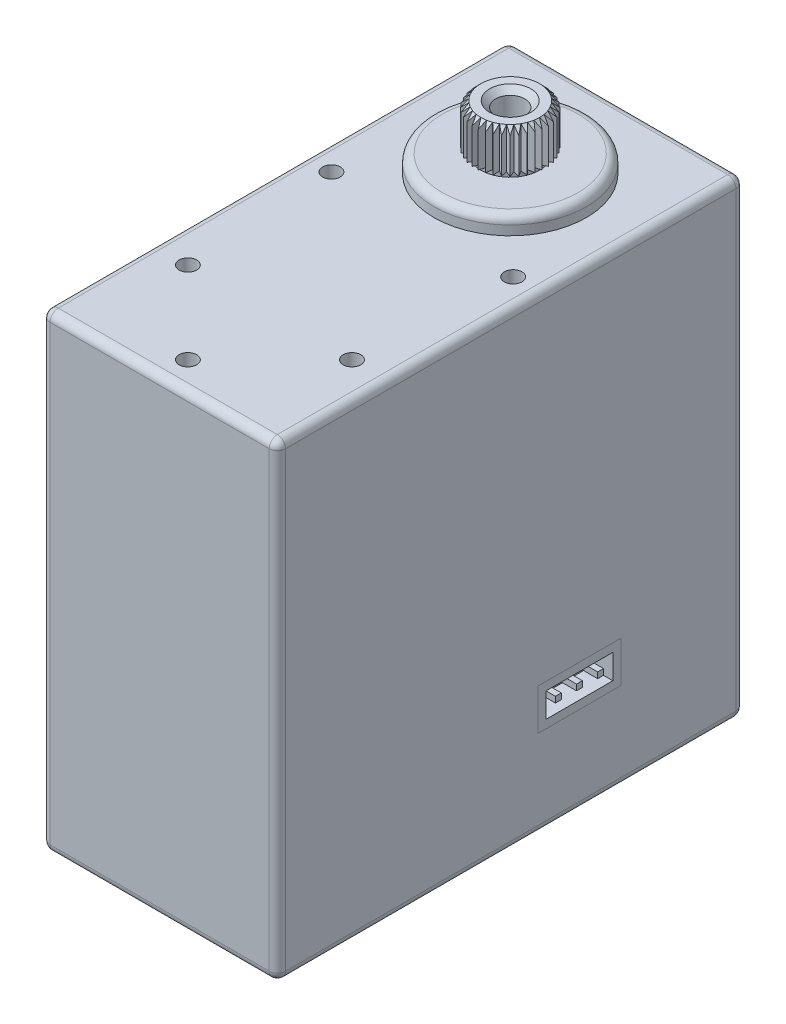
from build123d import *

# Parameters (mm, degrees)
CROQUIS2_R                 = 3
SALIENTE_EXTRUIR1_DEPTH    = 5.4
CROQUIS2_4_R               = 6.5
SALIENTE_EXTRUIR2_DEPTH    = 1.5
CROQUIS2_6_W               = 20.09
CROQUIS2_6_H               = 39.82
SALIENTE_EXTRUIR3_DEPTH    = 40
CROQUIS2_7_R               = 0.75
CORTAR_EXTRUIR1_DEPTH      = 2
CROQUIS2_8_R               = 6.5
SALIENTE_EXTRUIR4_DEPTH    = 41.5
CROQUIS2_10_R              = 3
SALIENTE_EXTRUIR5_DEPTH    = 45.7
CROQUIS3_R                 = 0.75
CORTAR_EXTRUIR2_DEPTH      = 2
CROQUIS5_W                 = 7.09
CROQUIS5_H                 = 3.5
CROQUIS5_W_2               = 5.69
CROQUIS5_H_2               = 2.1
CORTAR_EXTRUIR5_DEPTH      = 2
CROQUIS5_4_W               = 7.09
CROQUIS5_4_H               = 3.5
CROQUIS5_4_W_2             = 5.69
CROQUIS5_4_H_2             = 2.1
SALIENTE_EXTRUIR6_DEPTH    = 2
CROQUIS8_W                 = 7.09
CROQUIS8_H                 = 3.5
CROQUIS8_W_2               = 5.69
CROQUIS8_H_2               = 2.1
CORTAR_EXTRUIR6_DEPTH      = 2
CROQUIS8_6_W               = 7.09
CROQUIS8_6_H               = 3.5
CROQUIS8_6_W_2             = 5.69
CROQUIS8_6_H_2             = 2.1
SALIENTE_EXTRUIR9_DEPTH    = 2
REDONDEO1_R                = 0.7
REDONDEO2_R                = 0.7
CHAFL_N1_SIZE              = 0.5
CROQUIS9_R                 = 5.8
CORTAR_EXTRUIR13_DEPTH     = 3.5
CROQUIS10_R                = 3
CROQUIS10_R_2              = 2.5
CORTAR_EXTRUIR15_DEPTH     = 0.4
CROQUIS11_R                = 1.25
CORTAR_EXTRUIR16_DEPTH     = 4
CHAFL_N2_SIZE              = 0.5
CROQUIS12_W                = 0.5
CROQUIS12_H                = 0.5
SALIENTE_EXTRUIR13_DEPTH   = 2
SALIENTE_EXTRUIR13_2_DEPTH = 2
SALIENTE_EXTRUIR13_3_DEPTH = 2
CROQUIS13_W                = 0.5
CROQUIS13_H                = 0.5
SALIENTE_EXTRUIR14_DEPTH   = 2
SALIENTE_EXTRUIR14_2_DEPTH = 2
SALIENTE_EXTRUIR14_3_DEPTH = 2


with BuildPart() as part:
    # Croquis2 → Saliente-Extruir1 (new body)
    with BuildSketch(Plane(origin=(0, 0, 0), x_dir=(1, 0, 0), z_dir=(0, 1, 0))):
        with Locations(Location((0, 0, 0), (0, 0, 90))):
            Circle(CROQUIS2_R)
    extrude(amount=SALIENTE_EXTRUIR1_DEPTH)

    # Croquis2_4 → Saliente-Extruir2 (add)
    with BuildSketch(Plane(origin=(0, 0, 0), x_dir=(1, 0, 0), z_dir=(0, 1, 0))):
        with Locations(Location((0, 0, 0), (0, 0, 270))):
            Circle(CROQUIS2_4_R)
    extrude(amount=SALIENTE_EXTRUIR2_DEPTH)



with BuildPart() as body_2:
    # Croquis2_6 → Saliente-Extruir3 (new body)
    with BuildSketch(Plane(origin=(0, 0, 0), x_dir=(1, 0, 0), z_dir=(0, 1, 0))):
        with Locations((0, -10)):
            Rectangle(CROQUIS2_6_W, CROQUIS2_6_H)
    extrude(amount=-SALIENTE_EXTRUIR3_DEPTH)

    # Croquis2_7 → Cortar-Extruir1 (cut)
    with BuildSketch(Plane(origin=(0, 0, 0), x_dir=(1, 0, 0), z_dir=(0, 1, 0))):
        with Locations(Location((0, -27.5, 0), (0, 0, 270))):
            Circle(CROQUIS2_7_R)
        with Locations(Location((7, -20.5, 0), (0, 0, 270))):
            Circle(CROQUIS2_7_R)
        with Locations(Location((-7, -20.5, 0), (0, 0, 270))):
            Circle(CROQUIS2_7_R)
        with Locations(Location((-7.75, -7.5, 0), (0, 0, 270))):
            Circle(CROQUIS2_7_R)
        with Locations(Location((7.75, -7.5, 0), (0, 0, 270))):
            Circle(CROQUIS2_7_R)
    extrude(amount=-CORTAR_EXTRUIR1_DEPTH, mode=Mode.SUBTRACT)


with BuildPart() as part_1:
    add(part.part)

    add(body_2.part)  # Saliente-Extruir4 merges body 2
    # Croquis2_8 → Saliente-Extruir4 (add)
    with BuildSketch(Plane(origin=(0, 0, 0), x_dir=(1, 0, 0), z_dir=(0, 1, 0))):
        with Locations(Location((0, 0, 0), (0, 0, 270))):
            Circle(CROQUIS2_8_R)
    extrude(amount=-SALIENTE_EXTRUIR4_DEPTH)

    # Croquis2_10 → Saliente-Extruir5 (add)
    with BuildSketch(Plane(origin=(0, 0, 0), x_dir=(1, 0, 0), z_dir=(0, 1, 0))):
        with Locations(Location((0, 0, 0), (0, 0, 90))):
            Circle(CROQUIS2_10_R)
    extrude(amount=-SALIENTE_EXTRUIR5_DEPTH)

    # Croquis3 → Cortar-Extruir2 (cut)
    with BuildSketch(Plane.XZ.offset(40)):
        with Locations(Location((-7.5, 12.5, 0), (0, 0, 270))):
            Circle(CROQUIS3_R)
        with Locations(Location((-7.5, -7.5, 0), (0, 0, 270))):
            Circle(CROQUIS3_R)
        with Locations(Location((-7.5, 27.5, 0), (0, 0, 270))):
            Circle(CROQUIS3_R)
        with Locations(Location((7.5, -7.5, 0), (0, 0, 90))):
            Circle(CROQUIS3_R)
        with Locations(Location((7.5, 12.5, 0), (0, 0, 90))):
            Circle(CROQUIS3_R)
        with Locations(Location((7.5, 27.5, 0), (0, 0, 90))):
            Circle(CROQUIS3_R)
    extrude(amount=-CORTAR_EXTRUIR2_DEPTH, mode=Mode.SUBTRACT)

    # Croquis5 → Cortar-Extruir5 (cut)
    with BuildSketch(Plane(origin=(0, 0, -9.91), x_dir=(-1, 0, 0), z_dir=(0, 0, -1))):
        with Locations((0, -30.75)):
            Rectangle(CROQUIS5_W, CROQUIS5_H)
        with Locations((0, -30.75)):
            Rectangle(CROQUIS5_W_2, CROQUIS5_H_2, mode=Mode.SUBTRACT)
        with Locations((0, -30.75)):
            Rectangle(CROQUIS5_W_2, CROQUIS5_H_2)
    extrude(amount=-CORTAR_EXTRUIR5_DEPTH, mode=Mode.SUBTRACT)

    # Croquis8 → Cortar-Extruir6 (cut)
    with BuildSketch(Plane.ZY.offset(10.045)):
        with Locations((4.135, -30.75)):
            Rectangle(CROQUIS8_W, CROQUIS8_H)
        with Locations((4.135, -30.75)):
            Rectangle(CROQUIS8_W_2, CROQUIS8_H_2, mode=Mode.SUBTRACT)
        with Locations((4.135, -30.75)):
            Rectangle(CROQUIS8_W_2, CROQUIS8_H_2)
    cortar_extruir6 = extrude(amount=-CORTAR_EXTRUIR6_DEPTH, mode=Mode.SUBTRACT)

    # Simetría1: Cortar-Extruir6 across plane
    add(cortar_extruir6.mirror(Plane(origin=(0, 0, 0), x_dir=(0, 0, 1), z_dir=(1, 0, 0))), mode=Mode.SUBTRACT)

    # Redondeo1
    redondeo1_edges = [part_1.edges().sort_by_distance(p)[0] for p in [
        (0, 0, 29.91),
        (10.045, 0, 10),
        (-10.045, 0, 10),
        (-10.045, -20, 29.91),
        (0, 0, -9.91),
        (-10.045, -20, -9.91),
        (10.045, -40, 10),
        (10.045, -20, -9.91),
        (0, -40, 29.91),
        (10.045, -20, 29.91),
        (-10.045, -40, 10),
        (0, -40, -9.91),
    ]]
    fillet(redondeo1_edges, radius=REDONDEO1_R)

    # Redondeo2
    redondeo2_edges = [part_1.edges().sort_by_distance(p)[0] for p in [
        (0, -41.5, -6.5),
        (0, -41.5, 3),
        (0, 1.5, -6.5),
    ]]
    fillet(redondeo2_edges, radius=REDONDEO2_R)

    # Chaflán1
    chafl_n1_edges = [part_1.edges().sort_by_distance(p)[0] for p in [
        (0, 5.4, 3),
    ]]
    chamfer(chafl_n1_edges, length=CHAFL_N1_SIZE)

    # Croquis9 → Cortar-Extruir13 (cut)
    with BuildSketch(Plane(origin=(0, 5.4, 0), x_dir=(1, 0, 0), z_dir=(0, 1, 0))):
        Circle(CROQUIS9_R)
        Polygon((0, 2.5), (0.261467228, 2.988584094), (0.434120444, 2.462019383), (0.776457135, 2.897777479), (0.855050358, 2.349231552), (1.267854785, 2.718923361), (1.25, 2.165063509), (1.720729309, 2.457456133), (1.606969024, 1.915111108), (2.121320344, 2.121320344), (1.915111108, 1.606969024), (2.457456133, 1.720729309), (2.165063509, 1.25), (2.718923361, 1.267854785), (2.349231552, 0.855050358), (2.897777479, 0.776457135), (2.462019383, 0.434120444), (2.988584094, 0.261467228), (2.5, 0), (2.988584094, -0.261467228), (2.462019383, -0.434120444), (2.897777479, -0.776457135), (2.349231552, -0.855050358), (2.718923361, -1.267854785), (2.165063509, -1.25), (2.457456133, -1.720729309), (1.915111108, -1.606969024), (2.121320344, -2.121320344), (1.606969024, -1.915111108), (1.720729309, -2.457456133), (1.25, -2.165063509), (1.267854785, -2.718923361), (0.855050358, -2.349231552), (0.776457135, -2.897777479), (0.434120444, -2.462019383), (0.261467228, -2.988584094), (0, -2.5), (-0.261467228, -2.988584094), (-0.434120444, -2.462019383), (-0.776457135, -2.897777479), (-0.855050358, -2.349231552), (-1.267854785, -2.718923361), (-1.25, -2.165063509), (-1.720729309, -2.457456133), (-1.606969024, -1.915111108), (-2.121320344, -2.121320344), (-1.915111108, -1.606969024), (-2.457456133, -1.720729309), (-2.165063509, -1.25), (-2.718923361, -1.267854785), (-2.349231552, -0.855050358), (-2.897777479, -0.776457135), (-2.462019383, -0.434120444), (-2.988584094, -0.261467228), (-2.5, 0), (-2.988584094, 0.261467228), (-2.462019383, 0.434120444), (-2.897777479, 0.776457135), (-2.349231552, 0.855050358), (-2.718923361, 1.267854785), (-2.165063509, 1.25), (-2.457456133, 1.720729309), (-1.915111108, 1.606969024), (-2.121320344, 2.121320344), (-1.606969024, 1.915111108), (-1.720729309, 2.457456133), (-1.25, 2.165063509), (-1.267854785, 2.718923361), (-0.855050358, 2.349231552), (-0.776457135, 2.897777479), (-0.434120444, 2.462019383), (-0.261467228, 2.988584094), align=None, mode=Mode.SUBTRACT)
    extrude(amount=-CORTAR_EXTRUIR13_DEPTH, mode=Mode.SUBTRACT)

    # Croquis10 → Cortar-Extruir15 (cut)
    with BuildSketch(Plane(origin=(0, 1.9, 0), x_dir=(1, 0, 0), z_dir=(0, 1, 0))):
        with Locations(Location((0, 0, 0), (0, 0, 270))):
            Circle(CROQUIS10_R)
        with Locations(Location((0, 0, 0), (0, 0, 270))):
            Circle(CROQUIS10_R_2, mode=Mode.SUBTRACT)
    extrude(amount=-CORTAR_EXTRUIR15_DEPTH, mode=Mode.SUBTRACT)

    # Croquis11 → Cortar-Extruir16 (cut)
    with BuildSketch(Plane(origin=(0, 5.4, 0), x_dir=(1, 0, 0), z_dir=(0, 1, 0))):
        with Locations(Location((0, 0, 0), (0, 0, 270))):
            Circle(CROQUIS11_R)
    extrude(amount=-CORTAR_EXTRUIR16_DEPTH, mode=Mode.SUBTRACT)

    # Chaflán2
    chafl_n2_edges = [part_1.edges().sort_by_distance(p)[0] for p in [
        (0, 5.4, -1.25),
    ]]
    chamfer(chafl_n2_edges, length=CHAFL_N2_SIZE)


with BuildPart() as body_2_2:
    # Croquis5_4 → Saliente-Extruir6 (new body)
    with BuildSketch(Plane(origin=(0, 0, -9.91), x_dir=(-1, 0, 0), z_dir=(0, 0, -1))):
        with Locations((0, -30.75)):
            Rectangle(CROQUIS5_4_W, CROQUIS5_4_H)
        with Locations((0, -30.75)):
            Rectangle(CROQUIS5_4_W_2, CROQUIS5_4_H_2, mode=Mode.SUBTRACT)
    extrude(amount=-SALIENTE_EXTRUIR6_DEPTH)


with BuildPart() as body_3:
    # Croquis8_6 → Saliente-Extruir9 (new body)
    with BuildSketch(Plane.ZY.offset(10.045)):
        with Locations((4.135, -30.75)):
            Rectangle(CROQUIS8_6_W, CROQUIS8_6_H)
        with Locations((4.135, -30.75)):
            Rectangle(CROQUIS8_6_W_2, CROQUIS8_6_H_2, mode=Mode.SUBTRACT)
    extrude(amount=-SALIENTE_EXTRUIR9_DEPTH)


with BuildPart() as body_4:
    # Simetría4: mirrored copy
    add(body_3.part.mirror(Plane(origin=(0, 0, 0), x_dir=(0, 0, 1), z_dir=(1, 0, 0))))


with BuildPart() as body_5:
    # Croquis12 → Saliente-Extruir13 (new body)
    with BuildSketch(Plane(origin=(8.045, 0, 0), x_dir=(0, 0, -1), z_dir=(1, 0, 0))):
        with Locations((-2.335, -30.75)):
            Rectangle(CROQUIS12_W, CROQUIS12_H)
    saliente_extruir13 = extrude(amount=SALIENTE_EXTRUIR13_DEPTH)


with BuildPart() as body_6:
    # Croquis12 → Saliente-Extruir13 2 (new body)
    with BuildSketch(Plane(origin=(8.045, 0, 0), x_dir=(0, 0, -1), z_dir=(1, 0, 0))):
        with Locations((-4.135, -30.75)):
            Rectangle(CROQUIS12_W, CROQUIS12_H)
    saliente_extruir13_2 = extrude(amount=SALIENTE_EXTRUIR13_2_DEPTH)


with BuildPart() as body_7:
    # Croquis12 → Saliente-Extruir13 3 (new body)
    with BuildSketch(Plane(origin=(8.045, 0, 0), x_dir=(0, 0, -1), z_dir=(1, 0, 0))):
        with Locations((-5.935, -30.75)):
            Rectangle(CROQUIS12_W, CROQUIS12_H)
    saliente_extruir13_3 = extrude(amount=SALIENTE_EXTRUIR13_3_DEPTH)


with BuildPart() as part_2:
    add(part_1.part)

    # Simetría5: Saliente-Extruir13, Saliente-Extruir13 2, Saliente-Extruir13 3 across plane
    add(saliente_extruir13.mirror(Plane(origin=(0, 0, 0), x_dir=(0, 0, 1), z_dir=(1, 0, 0))))
    add(saliente_extruir13_2.mirror(Plane(origin=(0, 0, 0), x_dir=(0, 0, 1), z_dir=(1, 0, 0))))
    add(saliente_extruir13_3.mirror(Plane(origin=(0, 0, 0), x_dir=(0, 0, 1), z_dir=(1, 0, 0))))


with BuildPart() as body_8:
    # Croquis13 → Saliente-Extruir14 (new body)
    with BuildSketch(Plane(origin=(0, 0, -7.91), x_dir=(-1, 0, 0), z_dir=(0, 0, -1))):
        with Locations((-1.8, -30.75)):
            Rectangle(CROQUIS13_W, CROQUIS13_H)
    extrude(amount=SALIENTE_EXTRUIR14_DEPTH)


with BuildPart() as body_9:
    # Croquis13 → Saliente-Extruir14 2 (new body)
    with BuildSketch(Plane(origin=(0, 0, -7.91), x_dir=(-1, 0, 0), z_dir=(0, 0, -1))):
        with Locations((0, -30.75)):
            Rectangle(CROQUIS13_W, CROQUIS13_H)
    extrude(amount=SALIENTE_EXTRUIR14_2_DEPTH)


with BuildPart() as body_10:
    # Croquis13 → Saliente-Extruir14 3 (new body)
    with BuildSketch(Plane(origin=(0, 0, -7.91), x_dir=(-1, 0, 0), z_dir=(0, 0, -1))):
        with Locations((1.8, -30.75)):
            Rectangle(CROQUIS13_W, CROQUIS13_H)
    extrude(amount=SALIENTE_EXTRUIR14_3_DEPTH)


solid = Compound([body_2_2.part, body_3.part, body_4.part, body_5.part, body_6.part, body_7.part, part_2.part, body_8.part, body_9.part, body_10.part])
